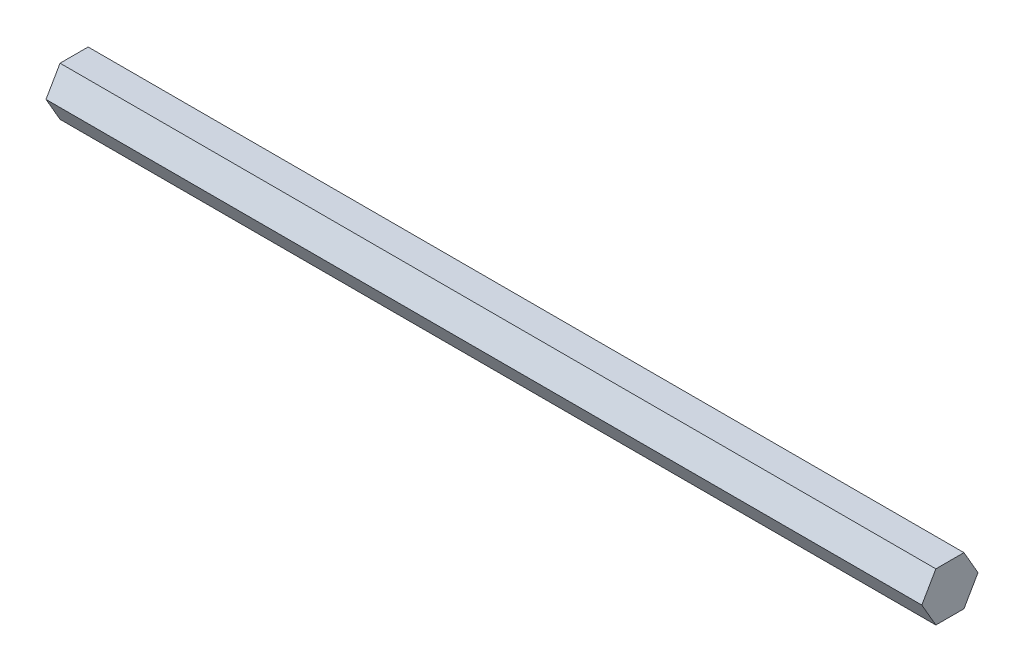
from build123d import *

# Parameters (mm, degrees)
BOSS_EXTRUDE1_DEPTH = 228.6


with BuildPart() as part:
    # Sketch1 → Boss-Extrude1 (new body)
    with BuildSketch(Plane(origin=(0, 0, 0), x_dir=(0, 0, -1), z_dir=(1, 0, 0))):
        Polygon((7.332348419, 0), (3.666174209, 6.35), (-3.666174209, 6.35), (-7.332348419, 0), (-3.666174209, -6.35), (3.666174209, -6.35), align=None)
    extrude(amount=BOSS_EXTRUDE1_DEPTH)


solid = part.part
